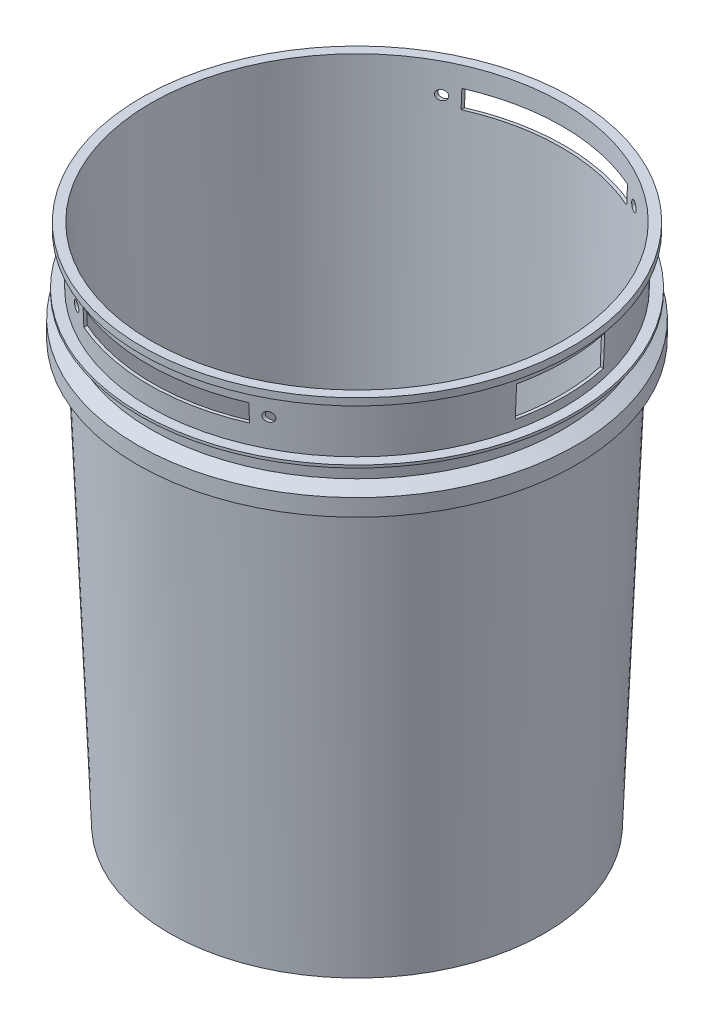
from build123d import *

# Parameters (mm, degrees)
SKETCH2_R          = 3.302
SKETCH2_W          = 116.84
SKETCH2_H          = 12.7
CUT_EXTRUDE1_DEPTH = 177.8
CUT_EXTRUDE2_REACH = 156.801
SKETCH3_W          = 62.2
SKETCH3_H          = 22.1


with BuildPart() as part:
    # Sketch1 → Revolve1 (revolve)
    with BuildSketch(Plane.XY):
        Polygon((0, 2), (0, 0), (132.375, 0), (145.180178243, 312.715931822), (153.550850285, 308.571177663), (153.550850285, 297.347080636), (154.800850285, 297.347080636), (154.800850285, 309.347080636), (145.236159596, 314.083055395), (145.727127461, 326.073007462), (152.897127461, 326.073007462), (152.897127461, 327.913007462), (145.802472288, 327.913007462), (147.415301724, 367.3), (150.95625, 367.3), (150.95625, 363.3), (151.95625, 363.3), (151.95625, 368.3), (145.25625, 368.3), (130.256896552, 2), align=None)
    revolve(axis=Axis((0, 0, 0), (0, 1, 0)))

    # Sketch2 → Cut-Extrude1 (cut, symmetric)
    with BuildSketch(Plane.XY):
        with Locations((67.82, 348.106503731)):
            Circle(SKETCH2_R)
        with Locations((-67.82, 348.106503731)):
            Circle(SKETCH2_R)
        with Locations((0, 348.106503731)):
            Rectangle(SKETCH2_W, SKETCH2_H)
    extrude(amount=CUT_EXTRUDE1_DEPTH, both=True, mode=Mode.SUBTRACT)

    # Sketch3 → Cut-Extrude2 (cut, up to next)
    with BuildSketch(Plane(origin=(0, 0, 0), x_dir=(0, 0, -1), z_dir=(1, 0, 0)), mode=Mode.PRIVATE) as cut_extrude2_sk1:
        with Locations((0, 345.618658854)):
            Rectangle(SKETCH3_W, SKETCH3_H)
    cut_extrude2_tool1 = extrude(cut_extrude2_sk1.sketch, amount=CUT_EXTRUDE2_REACH, mode=Mode.PRIVATE) & part.part
    add(cut_extrude2_tool1.solids().sort_by_distance((0, 345.618659, 0))[0], mode=Mode.SUBTRACT)


solid = part.part
